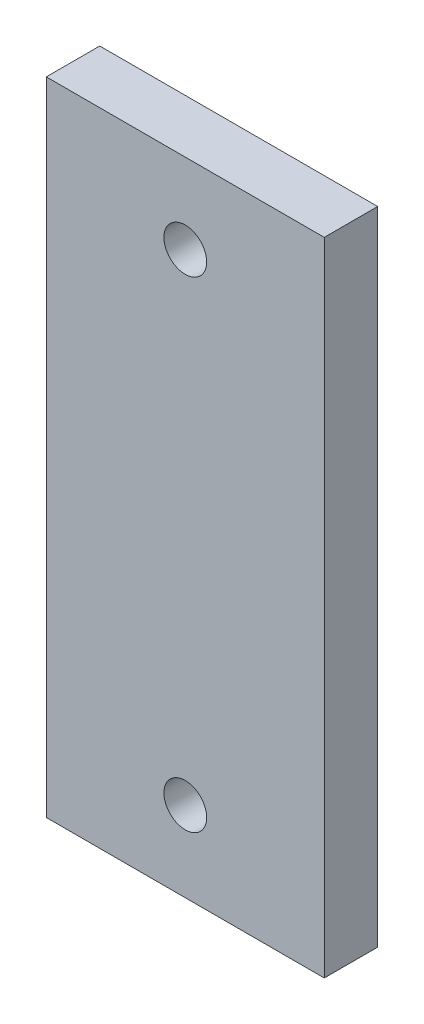
from build123d import *

# Parameters (mm, degrees)
SKETCH_1_W      = 26
SKETCH_1_H      = 60
SKETCH_1_R      = 2
EXTRUDE_1_DEPTH = 5


with BuildPart() as part:
    # 草图1 → 凸台-拉伸1 (new body)
    with BuildSketch(Plane.XY):
        with Locations((-24.496729184, 1.766332033)):
            Rectangle(SKETCH_1_W, SKETCH_1_H)
        with Locations((-24.496729184, 24.266332033)):
            Circle(SKETCH_1_R, mode=Mode.SUBTRACT)
        with Locations((-24.496729184, -20.733667967)):
            Circle(SKETCH_1_R, mode=Mode.SUBTRACT)
    extrude(amount=EXTRUDE_1_DEPTH)


solid = part.part
